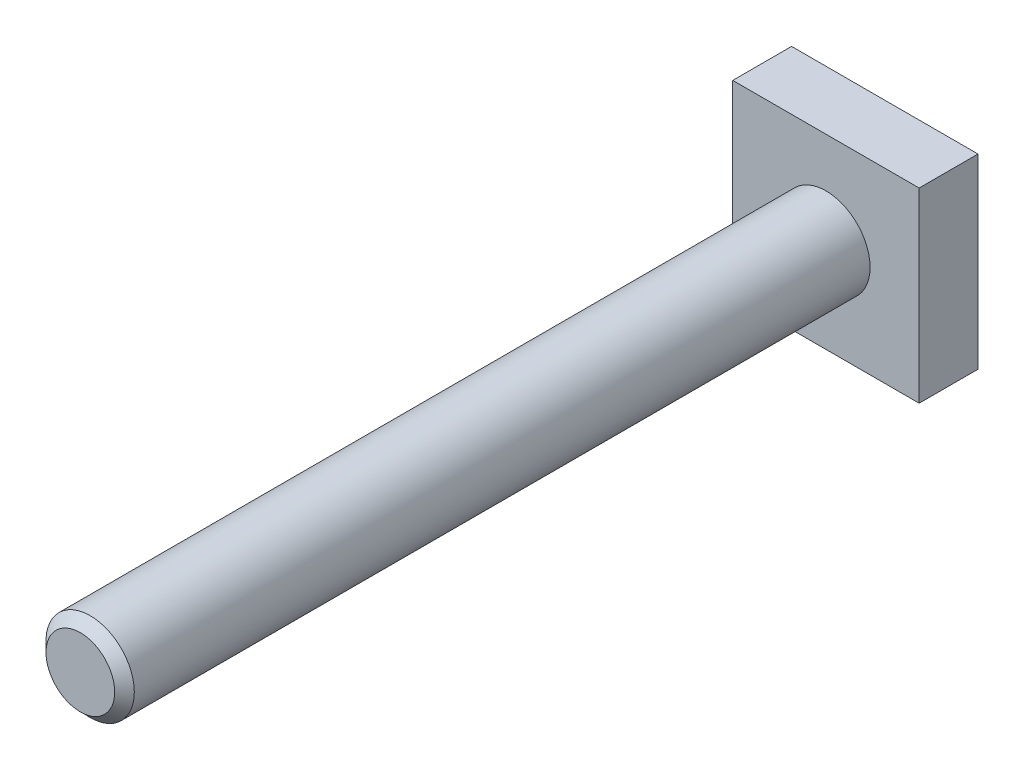
from build123d import *

# Parameters (mm, degrees)
SKETCH1_W           = 19
SKETCH1_H           = 19
BOSS_EXTRUDE1_DEPTH = 3
SKETCH2_R           = 4.5
BOSS_EXTRUDE2_DEPTH = 76
CHAMFER1_SIZE       = 1


with BuildPart() as part:
    # Sketch1 → Boss-Extrude1 (new body, symmetric)
    with BuildSketch(Plane.XY):
        Rectangle(SKETCH1_W, SKETCH1_H)
    extrude(amount=BOSS_EXTRUDE1_DEPTH, both=True)

    # Sketch2 → Boss-Extrude2 (add)
    with BuildSketch(Plane.XY.offset(3)):
        Circle(SKETCH2_R)
    extrude(amount=BOSS_EXTRUDE2_DEPTH)

    # Chamfer1
    chamfer1_edges = [part.edges().sort_by_distance(p)[0] for p in [
        (-4.5, 0, 79),
    ]]
    chamfer(chamfer1_edges, length=CHAMFER1_SIZE)


solid = part.part
